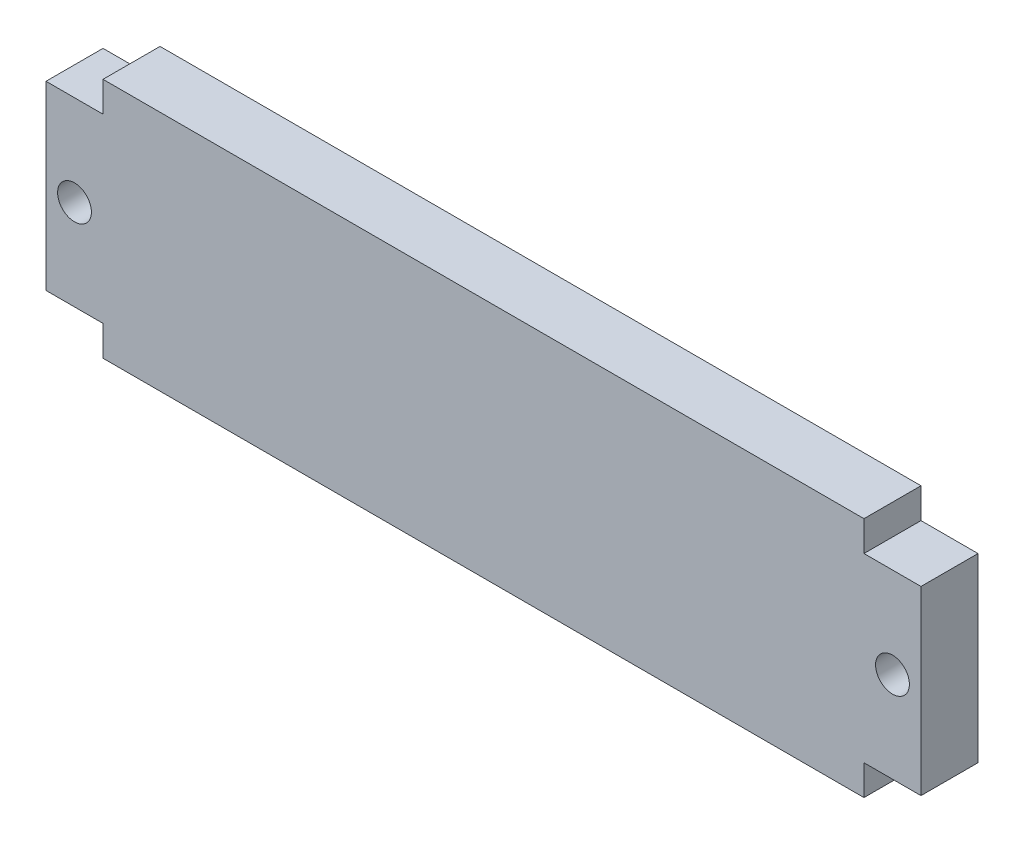
from build123d import *

# Parameters (mm, degrees)
SKETCH1_W           = 91.9988
SKETCH1_H           = 25.4
BOSS_EXTRUDE1_DEPTH = 5.9944
SKETCH2_R           = 1.778
CUT_EXTRUDE1_DEPTH  = 6.9944
SKETCH3_W           = 5.9944
SKETCH3_H           = 3.175
CUT_EXTRUDE2_DEPTH  = 6.9944


with BuildPart() as part:
    # Sketch1 → Boss-Extrude1 (new body)
    with BuildSketch(Plane.XY):
        with Locations((45.9994, 12.7)):
            Rectangle(SKETCH1_W, SKETCH1_H)
    extrude(amount=-BOSS_EXTRUDE1_DEPTH)

    # Sketch2 → Cut-Extrude1 (cut, through all)
    with BuildSketch(Plane.XY):
        with Locations((2.9972, 12.7)):
            Circle(SKETCH2_R)
        with Locations((89.0016, 12.7)):
            Circle(SKETCH2_R)
    extrude(amount=-CUT_EXTRUDE1_DEPTH, mode=Mode.SUBTRACT)

    # Sketch3 → Cut-Extrude2 (cut, through all)
    with BuildSketch(Plane.XY):
        with Locations((2.9972, 23.8125)):
            Rectangle(SKETCH3_W, SKETCH3_H)
        with Locations((89.0016, 23.8125)):
            Rectangle(SKETCH3_W, SKETCH3_H)
        with Locations((89.0016, 1.5875)):
            Rectangle(SKETCH3_W, SKETCH3_H)
        with Locations((2.9972, 1.5875)):
            Rectangle(SKETCH3_W, SKETCH3_H)
    extrude(amount=-CUT_EXTRUDE2_DEPTH, mode=Mode.SUBTRACT)


solid = part.part
